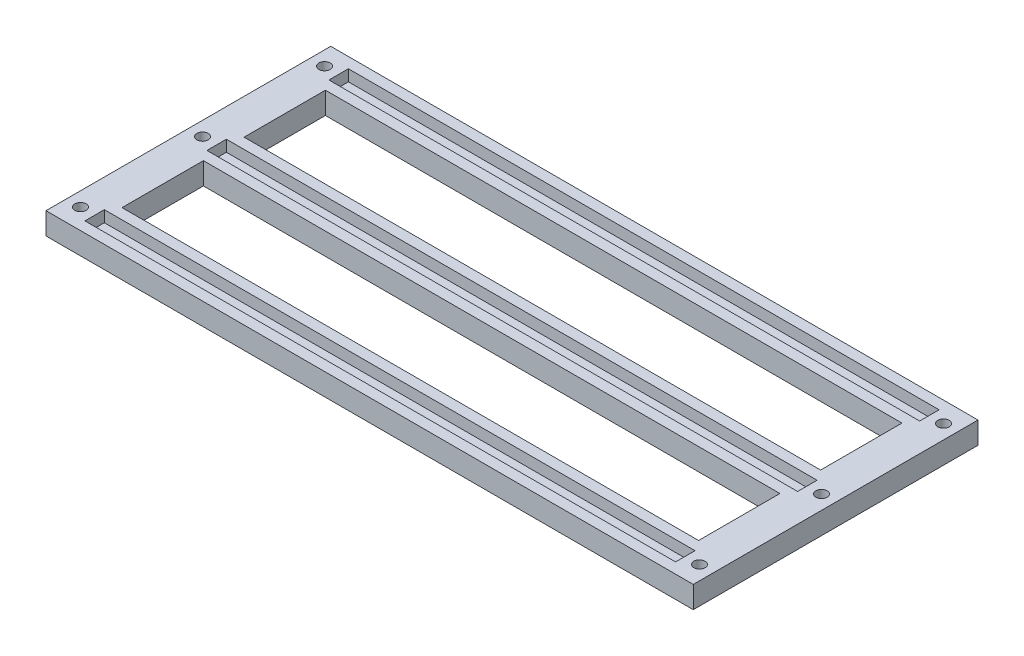
from build123d import *

# Parameters (mm, degrees)
SKETCH1_W           = 183
SKETCH1_H           = 80.5
SKETCH1_W_2         = 163
SKETCH1_H_2         = 23
SKETCH1_R           = 1.6
BOSS_EXTRUDE1_DEPTH = 3.2
SKETCH1_3_W         = 183
SKETCH1_3_H         = 80.5
SKETCH1_3_R         = 1.6
SKETCH1_3_W_2       = 163
SKETCH1_3_H_2       = 23
BOSS_EXTRUDE2_DEPTH = 3


with BuildPart() as part:
    # Sketch1 → Boss-Extrude1 (new body)
    with BuildSketch(Plane(origin=(0, 0, 0), x_dir=(1, 0, 0), z_dir=(0, 1, 0))):
        Rectangle(SKETCH1_W, SKETCH1_H)
        with Locations((0, 17.25)):
            Rectangle(SKETCH1_W_2, SKETCH1_H_2, mode=Mode.SUBTRACT)
        Polygon((83.5, 2.75), (83.5, -2.75), (81.5, -2.75), (-81.5, -2.75), (-83.5, -2.75), (-83.5, 2.75), align=None, mode=Mode.SUBTRACT)
        with Locations((0, -17.25)):
            Rectangle(SKETCH1_W_2, SKETCH1_H_2, mode=Mode.SUBTRACT)
        Polygon((83.5, -31.75), (83.5, -37.25), (-81.5, -37.25), (-83.5, -37.25), (-83.5, -31.75), align=None, mode=Mode.SUBTRACT)
        Polygon((81.5, 37.25), (83.5, 37.25), (83.5, 31.75), (-83.5, 31.75), (-83.5, 37.25), align=None, mode=Mode.SUBTRACT)
        with Locations((-87.5, -34.5)):
            Circle(SKETCH1_R, mode=Mode.SUBTRACT)
        with Locations((-87.5, 0)):
            Circle(SKETCH1_R, mode=Mode.SUBTRACT)
        with Locations((-87.5, 34.5)):
            Circle(SKETCH1_R, mode=Mode.SUBTRACT)
        with Locations((87.5, 34.5)):
            Circle(SKETCH1_R, mode=Mode.SUBTRACT)
        with Locations((87.5, -34.5)):
            Circle(SKETCH1_R, mode=Mode.SUBTRACT)
        with Locations((87.5, 0)):
            Circle(SKETCH1_R, mode=Mode.SUBTRACT)
    extrude(amount=BOSS_EXTRUDE1_DEPTH)

    # Sketch1_3 → Boss-Extrude2 (add)
    with BuildSketch(Plane(origin=(0, 0, 0), x_dir=(1, 0, 0), z_dir=(0, 1, 0))):
        Rectangle(SKETCH1_3_W, SKETCH1_3_H)
        with Locations((-87.5, -34.5)):
            Circle(SKETCH1_3_R, mode=Mode.SUBTRACT)
        with Locations((0, -17.25)):
            Rectangle(SKETCH1_3_W_2, SKETCH1_3_H_2, mode=Mode.SUBTRACT)
        with Locations((87.5, -34.5)):
            Circle(SKETCH1_3_R, mode=Mode.SUBTRACT)
        with Locations((-87.5, 0)):
            Circle(SKETCH1_3_R, mode=Mode.SUBTRACT)
        with Locations((0, 17.25)):
            Rectangle(SKETCH1_3_W_2, SKETCH1_3_H_2, mode=Mode.SUBTRACT)
        with Locations((-87.5, 34.5)):
            Circle(SKETCH1_3_R, mode=Mode.SUBTRACT)
        with Locations((87.5, 0)):
            Circle(SKETCH1_3_R, mode=Mode.SUBTRACT)
        with Locations((87.5, 34.5)):
            Circle(SKETCH1_3_R, mode=Mode.SUBTRACT)
    extrude(amount=-BOSS_EXTRUDE2_DEPTH)


solid = part.part
